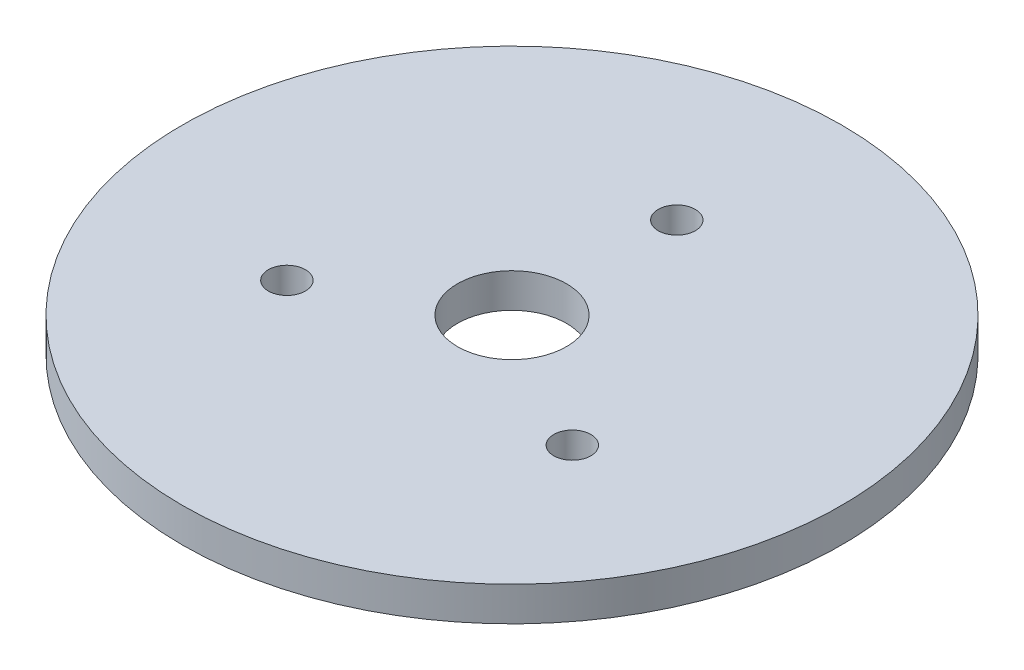
from build123d import *

# Parameters (mm, degrees)
SKETCH1_R           = 23.99268
SKETCH1_R_2         = 1.35
BOSS_EXTRUDE1_DEPTH = 2.5
SKETCH4_R           = 3.96875
CUT_EXTRUDE3_DEPTH  = 3.5


with BuildPart() as part:
    # Sketch1 → Boss-Extrude1 (new body)
    with BuildSketch(Plane(origin=(0, 0, 0), x_dir=(1, 0, 0), z_dir=(0, 1, 0))):
        Circle(SKETCH1_R)
        with Locations((0, 11.99634)):
            Circle(SKETCH1_R_2, mode=Mode.SUBTRACT)
        with Locations((10.389135192, -5.99817)):
            Circle(SKETCH1_R_2, mode=Mode.SUBTRACT)
        with Locations((-10.389135192, -5.99817)):
            Circle(SKETCH1_R_2, mode=Mode.SUBTRACT)
    extrude(amount=BOSS_EXTRUDE1_DEPTH)

    # Sketch4 → Cut-Extrude3 (cut, through all)
    with BuildSketch(Plane(origin=(0, 2.5, 0), x_dir=(1, 0, 0), z_dir=(0, 1, 0))):
        Circle(SKETCH4_R)
    extrude(amount=-CUT_EXTRUDE3_DEPTH, mode=Mode.SUBTRACT)


solid = part.part
